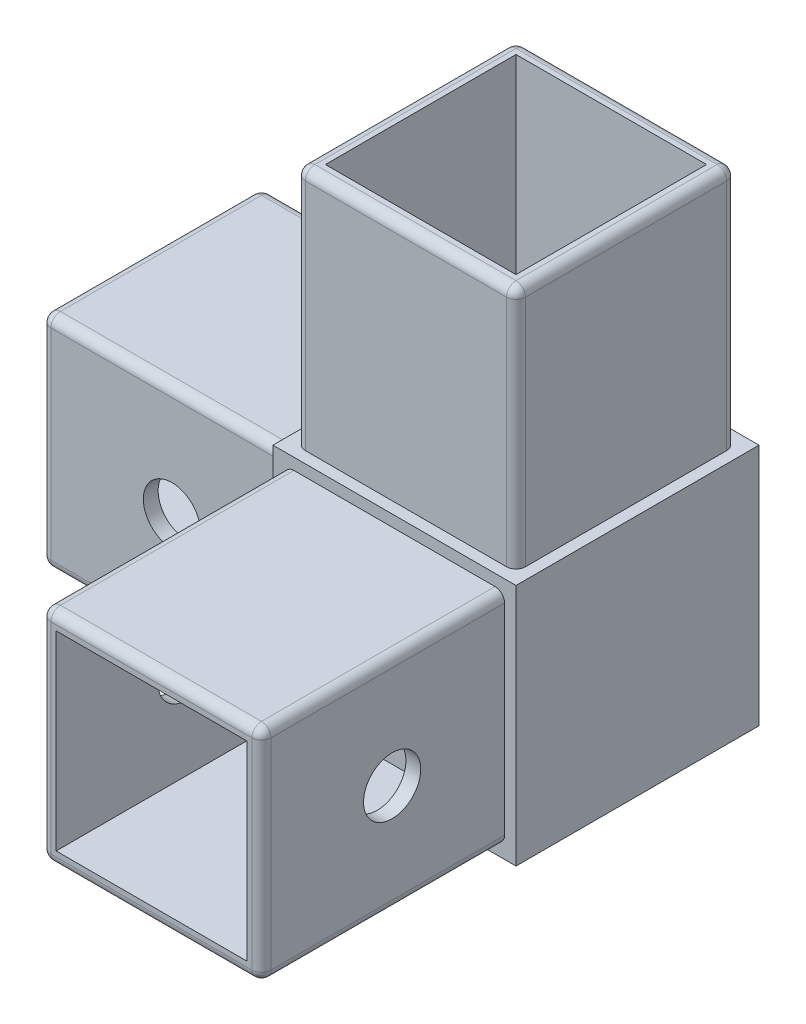
from build123d import *

# Parameters (mm, degrees)
SKETCH1_W                = 25.5
SKETCH1_H                = 25.5
BOSS_EXTRUDE1_DEPTH      = 25.5
SKETCH2_W                = 23.1
SKETCH2_H                = 23.1
SKETCH2_W_2              = 20
SKETCH2_H_2              = 20
BOSS_EXTRUDE2_DEPTH      = 25.5
SKETCH3_W                = 23.1
SKETCH3_H                = 23.1
SKETCH3_W_2              = 20
SKETCH3_H_2              = 20
BOSS_EXTRUDE3_DEPTH      = 25.5
SKETCH4_W                = 23.1
SKETCH4_H                = 23.1
SKETCH4_W_2              = 20
SKETCH4_H_2              = 20
BOSS_EXTRUDE4_DEPTH      = 25.5
FILLET4_R                = 1
F_6_0_6_DIAMETER_HOLE1_D = 6
F_6_0_6_DIAMETER_HOLE2_D = 6


with BuildPart() as part:
    # Sketch1 → Boss-Extrude1 (new body)
    with BuildSketch(Plane.XY):
        Rectangle(SKETCH1_W, SKETCH1_H)
    extrude(amount=BOSS_EXTRUDE1_DEPTH)

    # Sketch2 → Boss-Extrude2 (add)
    with BuildSketch(Plane(origin=(0, 12.75, 0), x_dir=(1, 0, 0), z_dir=(0, 1, 0))):
        with Locations((0, -12.75)):
            Rectangle(SKETCH2_W, SKETCH2_H)
        with Locations((0, -12.75)):
            Rectangle(SKETCH2_W_2, SKETCH2_H_2, mode=Mode.SUBTRACT)
    extrude(amount=BOSS_EXTRUDE2_DEPTH)

    # Sketch3 → Boss-Extrude3 (add)
    with BuildSketch(Plane.XY.offset(25.5)):
        Rectangle(SKETCH3_W, SKETCH3_H)
        Rectangle(SKETCH3_W_2, SKETCH3_H_2, mode=Mode.SUBTRACT)
    extrude(amount=BOSS_EXTRUDE3_DEPTH)

    # Sketch4 → Boss-Extrude4 (add)
    with BuildSketch(Plane.ZY.offset(12.75)):
        with Locations((12.75, 0)):
            Rectangle(SKETCH4_W, SKETCH4_H)
        with Locations((12.75, 0)):
            Rectangle(SKETCH4_W_2, SKETCH4_H_2, mode=Mode.SUBTRACT)
    extrude(amount=BOSS_EXTRUDE4_DEPTH)

    # Fillet4
    fillet4_edges = [part.edges().sort_by_distance(p)[0] for p in [
        (11.55, 38.25, 12.75),
        (0, 38.25, 1.2),
        (-11.55, 38.25, 12.75),
        (0, 38.25, 24.3),
        (11.55, 25.5, 24.3),
        (11.55, 25.5, 1.2),
        (-11.55, 25.5, 1.2),
        (-11.55, 25.5, 24.3),
        (11.55, 0, 51),
        (0, 11.55, 51),
        (-11.55, 0, 51),
        (0, -11.55, 51),
        (11.55, -11.55, 38.25),
        (11.55, 11.55, 38.25),
        (-11.55, 11.55, 38.25),
        (-11.55, -11.55, 38.25),
        (-38.25, 0, 24.3),
        (-38.25, 11.55, 12.75),
        (-38.25, 0, 1.2),
        (-38.25, -11.55, 12.75),
        (-25.5, -11.55, 24.3),
        (-25.5, 11.55, 24.3),
        (-25.5, 11.55, 1.2),
        (-25.5, -11.55, 1.2),
    ]]
    fillet(fillet4_edges, radius=FILLET4_R)

    # Ø6.0 (6) Diameter Hole1 (through all)
    with Locations(Plane(origin=(0, 0, 1.2), x_dir=(-1, 0, 0), z_dir=(0, 0, -1))):
        with Locations((24.55, -0.15)):
            Hole(F_6_0_6_DIAMETER_HOLE1_D / 2)

    # Ø6.0 (6) Diameter Hole2 (through all)
    with Locations(Plane(origin=(11.55, 0, 0), x_dir=(0, 0, -1), z_dir=(1, 0, 0))):
        with Locations((-37.3, -0.15)):
            Hole(F_6_0_6_DIAMETER_HOLE2_D / 2)


solid = part.part
